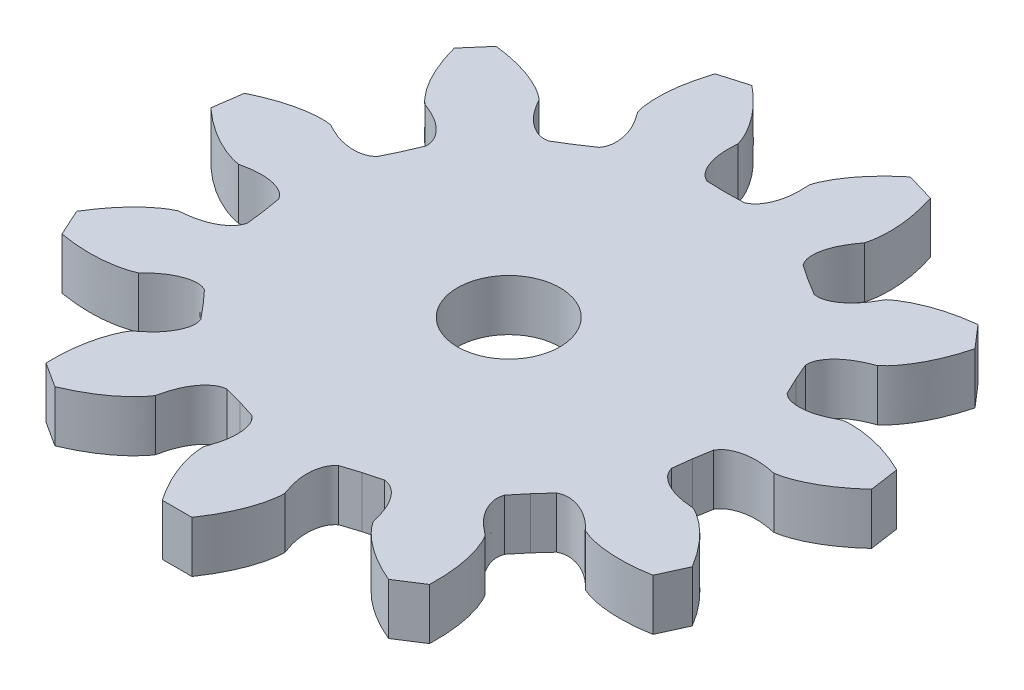
from build123d import *

# Parameters (mm, degrees)
ESBO_O1_R                = 4
RESSALTO_EXTRUS_O1_DEPTH = 4


with BuildPart() as part:
    # Esboço1 → Ressalto-extrusão1 (new body)
    with BuildSketch(Plane(origin=(0, 0, 0), x_dir=(1, 0, 0), z_dir=(0, 1, 0))):
        with BuildLine():
            Line((-18.79425391, 17.817601507), (-20.310943501, 16.067248601))
            add(Edge.make_bspline(
                [(-20.310943501, 16.067248601), (-20.071277367, 15.149373364), (-19.587508942, 13.795380648), (-18.623283394, 12.156256417), (-18.017526796, 11.428490265), (-17.661404245, 11.122721576)],
                knots=[0.009055561, 0.009055561, 0.009055561, 0.009055561, 0.503056033, 0.75005627, 0.997056506, 0.997056506, 0.997056506, 0.997056506], degree=3))
            add(Edge.make_bspline(
                [(-17.661404245, 11.122721576), (-17.338449221, 10.997306174), (-16.694924793, 10.741620444), (-15.801553421, 10.176642889), (-15.182066986, 9.539164967), (-14.886283931, 8.976589612), (-14.806778016, 8.61451277), (-14.804415739, 8.434534603), (-14.803014561, 8.344270523)],
                knots=[0.004160286, 0.004160286, 0.004160286, 0.004160286, 0.254421519, 0.504682752, 0.754943984, 0.880074601, 0.942639909, 1.005205217, 1.005205217, 1.005205217, 1.005205217], degree=3))
            Line((-14.803014561, 8.344270523), (-15.372758342, 7.0205046))
            Line((-15.372758342, 7.0205046), (-16.000091263, 5.723038543))
            add(Edge.make_bspline(
                [(-16.000091263, 5.723038543), (-16.069225887, 5.664987094), (-16.206791283, 5.548911773), (-16.532496032, 5.371888455), (-17.151358828, 5.22701792), (-18.03880983, 5.27773537), (-19.050825198, 5.582918909), (-19.665478418, 5.901823726), (-19.971751594, 6.063767268)],
                knots=[-0.005205218, -0.005205218, -0.005205218, -0.005205218, 0.057360091, 0.119925399, 0.245056015, 0.495317248, 0.745578481, 0.995839713, 0.995839713, 0.995839713, 0.995839713], degree=3))
            add(Edge.make_bspline(
                [(-19.971751594, 6.063767268), (-20.436046819, 6.132670877), (-21.382741993, 6.113885793), (-23.25294292, 5.769200941), (-24.593023331, 5.248132184), (-25.443655143, 4.828179416)],
                knots=[0.002943495, 0.002943495, 0.002943495, 0.002943495, 0.249943731, 0.496943967, 0.990944438, 0.990944438, 0.990944438, 0.990944438], degree=3))
            Line((-25.443655143, 4.828179416), (-25.773263393, 2.535704551))
            add(Edge.make_bspline(
                [(-25.773263393, 2.535704551), (-25.075402593, 1.89311206), (-23.936406968, 1.015605861), (-22.239071355, 0.157986499), (-21.336016389, -0.126752605), (-20.871116001, -0.191447208)],
                knots=[0.009055561, 0.009055561, 0.009055561, 0.009055561, 0.503056033, 0.75005627, 0.997056506, 0.997056506, 0.997056506, 0.997056506], degree=3))
            add(Edge.make_bspline(
                [(-20.871116001, -0.191447208), (-20.531624261, -0.12235069), (-19.85202292, 0.010468359), (-18.79502117, 0.018172024), (-17.929229433, -0.183188877), (-17.376249694, -0.496544989), (-17.113611541, -0.758159269), (-17.014320725, -0.908289395), (-16.964341533, -0.983466837)],
                knots=[0.004160286, 0.004160286, 0.004160286, 0.004160286, 0.254421519, 0.504682752, 0.754943984, 0.880074601, 0.942639909, 1.005205217, 1.005205217, 1.005205217, 1.005205217], degree=3))
            Line((-16.964341533, -0.983466837), (-16.727958611, -2.40511634))
            Line((-16.727958611, -2.40511634), (-16.554241537, -3.835776027))
            add(Edge.make_bspline(
                [(-16.554241537, -3.835776027), (-16.5810163, -3.921989013), (-16.633988619, -4.094011255), (-16.812282859, -4.419022029), (-17.254580448, -4.875477366), (-18.028571662, -5.312603367), (-19.044927844, -5.603003452), (-19.734419998, -5.667030268), (-20.079626678, -5.696378472)],
                knots=[-0.005205218, -0.005205218, -0.005205218, -0.005205218, 0.057360091, 0.119925399, 0.245056015, 0.495317248, 0.745578481, 0.995839713, 0.995839713, 0.995839713, 0.995839713], degree=3))
            add(Edge.make_bspline(
                [(-20.079626678, -5.696378472), (-20.50746878, -5.889430017), (-21.293723456, -6.417055088), (-22.680685893, -7.718129396), (-23.526322235, -8.880982497), (-24.014875643, -9.694155524)],
                knots=[0.002943495, 0.002943495, 0.002943495, 0.002943495, 0.249943731, 0.496943967, 0.990944438, 0.990944438, 0.990944438, 0.990944438], degree=3))
            Line((-24.014875643, -9.694155524), (-23.052754264, -11.800907778))
            add(Edge.make_bspline(
                [(-23.052754264, -11.800907778), (-22.11826467, -11.964198948), (-20.685664908, -12.086616612), (-18.794111294, -11.890443016), (-17.880471532, -11.641752419), (-17.454395895, -11.444832857)],
                knots=[0.009055561, 0.009055561, 0.009055561, 0.009055561, 0.503056033, 0.75005627, 0.997056506, 0.997056506, 0.997056506, 0.997056506], degree=3))
            add(Edge.make_bspline(
                [(-17.454395895, -11.444832857), (-17.206153667, -11.203162074), (-16.706244038, -10.724007355), (-15.821202497, -10.14606833), (-14.983988217, -9.847381547), (-14.349378953, -9.812030065), (-13.986994322, -9.890121097), (-13.822299097, -9.962737927), (-13.739609932, -9.998960425)],
                knots=[0.004160286, 0.004160286, 0.004160286, 0.004160286, 0.254421519, 0.504682752, 0.754943984, 0.880074601, 0.942639909, 1.005205217, 1.005205217, 1.005205217, 1.005205217], degree=3))
            Line((-13.739609932, -9.998960425), (-12.772150215, -11.067129835))
            Line((-12.772150215, -11.067129835), (-11.85253709, -12.17675881))
            add(Edge.make_bspline(
                [(-11.85253709, -12.17675881), (-11.828451194, -12.26376132), (-11.780012099, -12.437114637), (-11.754288668, -12.806924242), (-11.879594691, -13.430043037), (-12.294389376, -14.216228072), (-12.992400465, -15.010011806), (-13.537822665, -15.436642194), (-13.812362167, -15.647964295)],
                knots=[-0.005205218, -0.005205218, -0.005205218, -0.005205218, 0.057360091, 0.119925399, 0.245056015, 0.495317248, 0.745578481, 0.995839713, 0.995839713, 0.995839713, 0.995839713], degree=3))
            add(Edge.make_bspline(
                [(-13.812362167, -15.647964295), (-14.067914302, -16.041678493), (-14.444098176, -16.910626319), (-14.907471349, -18.755008183), (-14.990180058, -20.190447985), (-14.961542808, -21.138664581)],
                knots=[0.002943495, 0.002943495, 0.002943495, 0.002943495, 0.249943731, 0.496943967, 0.990944438, 0.990944438, 0.990944438, 0.990944438], degree=3))
            Line((-14.961542808, -21.138664581), (-13.013158538, -22.390815268))
            add(Edge.make_bspline(
                [(-13.013158538, -22.390815268), (-12.138733995, -22.022961324), (-10.867370397, -21.35142371), (-9.382153691, -20.163740888), (-8.748003301, -19.460578096), (-8.496028419, -19.064564938)],
                knots=[0.009055561, 0.009055561, 0.009055561, 0.009055561, 0.503056033, 0.75005627, 0.997056506, 0.997056506, 0.997056506, 0.997056506], degree=3))
            add(Edge.make_bspline(
                [(-8.496028419, -19.064564938), (-8.417850857, -18.727048657), (-8.256350714, -18.053686507), (-7.824263818, -17.089003678), (-7.281436614, -16.385100154), (-6.766681783, -16.012264924), (-6.419605232, -15.882039357), (-6.24179517, -15.854087561), (-6.152649257, -15.839854727)],
                knots=[0.004160286, 0.004160286, 0.004160286, 0.004160286, 0.254421519, 0.504682752, 0.754943984, 0.880074601, 0.942639909, 1.005205217, 1.005205217, 1.005205217, 1.005205217], degree=3))
            Line((-6.152649257, -15.839854727), (-4.761274369, -16.215407805))
            Line((-4.761274369, -16.215407805), (-3.387735863, -16.651706709))
            add(Edge.make_bspline(
                [(-3.387735863, -16.651706709), (-3.32043641, -16.711876059), (-3.185964971, -16.831521997), (-2.964390877, -17.128718497), (-2.732921557, -17.720664936), (-2.65682533, -18.606300812), (-2.814877738, -19.651447468), (-3.043062289, -20.305229293), (-3.159770262, -20.631432018)],
                knots=[-0.005205218, -0.005205218, -0.005205218, -0.005205218, 0.057360091, 0.119925399, 0.245056015, 0.495317248, 0.745578481, 0.995839713, 0.995839713, 0.995839713, 0.995839713], degree=3))
            add(Edge.make_bspline(
                [(-3.159770262, -20.631432018), (-3.161896432, -21.100807393), (-3.008573782, -22.035193179), (-2.401239983, -23.837304388), (-1.694761628, -25.089588897), (-1.158025845, -25.871796993)],
                knots=[0.002943495, 0.002943495, 0.002943495, 0.002943495, 0.249943731, 0.496943967, 0.990944438, 0.990944438, 0.990944438, 0.990944438], degree=3))
            Line((-1.158025845, -25.871796993), (1.158023077, -25.871797117))
            add(Edge.make_bspline(
                [(1.158023077, -25.871797117), (1.694758956, -25.089589087), (2.401237429, -23.837304642), (3.008571419, -22.035193498), (3.161894168, -21.10080773), (3.15976805, -20.631432355)],
                knots=[0.009055561, 0.009055561, 0.009055561, 0.009055561, 0.503056033, 0.75005627, 0.997056506, 0.997056506, 0.997056506, 0.997056506], degree=3))
            add(Edge.make_bspline(
                [(3.15976805, -20.631432355), (3.043060122, -20.305229611), (2.814875625, -19.651447754), (2.656823339, -18.606301103), (2.732919665, -17.720665234), (2.964389042, -17.128718806), (3.185963159, -16.831522338), (3.320434621, -16.711876414), (3.387734085, -16.651707073)],
                knots=[0.004160286, 0.004160286, 0.004160286, 0.004160286, 0.254421519, 0.504682752, 0.754943984, 0.880074601, 0.942639909, 1.005205217, 1.005205217, 1.005205217, 1.005205217], degree=3))
            Line((3.387734085, -16.651707073), (4.761272447, -16.215408369))
            Line((4.761272447, -16.215408369), (6.152647564, -15.839855383))
            add(Edge.make_bspline(
                [(6.152647564, -15.839855383), (6.241793473, -15.85408823), (6.419603524, -15.88204005), (6.766680072, -16.012265656), (7.281434862, -16.385100926), (7.824261986, -17.089004509), (8.256348782, -18.053687409), (8.417848862, -18.727049561), (8.496026376, -19.06456585)],
                knots=[-0.005205218, -0.005205218, -0.005205218, -0.005205218, 0.057360091, 0.119925399, 0.245056015, 0.495317248, 0.745578481, 0.995839713, 0.995839713, 0.995839713, 0.995839713], degree=3))
            add(Edge.make_bspline(
                [(8.496026376, -19.06456585), (8.748001214, -19.460579036), (9.38215153, -20.163741897), (10.867368112, -21.351424877), (12.138731644, -22.022962609), (13.013156142, -22.39081666)],
                knots=[0.002943495, 0.002943495, 0.002943495, 0.002943495, 0.249943731, 0.496943967, 0.990944438, 0.990944438, 0.990944438, 0.990944438], degree=3))
            Line((13.013156142, -22.39081666), (14.961540547, -21.138666183))
            add(Edge.make_bspline(
                [(14.961540547, -21.138666183), (14.990177913, -20.190449589), (14.907469338, -18.755009777), (14.44409636, -16.910627865), (14.06791258, -16.041680001), (13.812360489, -15.647965775)],
                knots=[0.009055561, 0.009055561, 0.009055561, 0.009055561, 0.503056033, 0.75005627, 0.997056506, 0.997056506, 0.997056506, 0.997056506], degree=3))
            add(Edge.make_bspline(
                [(13.812360489, -15.647965775), (13.537821014, -15.436643633), (12.992398842, -15.01001319), (12.294387858, -14.216229394), (11.879593261, -13.43004431), (11.754287292, -12.806925494), (11.780010759, -12.437115903), (11.828449881, -12.263762586), (11.852535791, -12.176760078)],
                knots=[0.004160286, 0.004160286, 0.004160286, 0.004160286, 0.254421519, 0.504682752, 0.754943984, 0.880074601, 0.942639909, 1.005205217, 1.005205217, 1.005205217, 1.005205217], degree=3))
            Line((11.852535791, -12.176760078), (12.772148903, -11.067131349))
            Line((12.772148903, -11.067131349), (13.739608862, -9.998961891))
            add(Edge.make_bspline(
                [(13.739608862, -9.998961891), (13.822298031, -9.962739408), (13.986993259, -9.890122603), (14.34937791, -9.812031606), (14.983987161, -9.847383143), (15.821201404, -10.14607002), (16.7062429, -10.724009159), (17.206152477, -11.203163913), (17.454394669, -11.444834728)],
                knots=[-0.005205218, -0.005205218, -0.005205218, -0.005205218, 0.057360091, 0.119925399, 0.245056015, 0.495317248, 0.745578481, 0.995839713, 0.995839713, 0.995839713, 0.995839713], degree=3))
            add(Edge.make_bspline(
                [(17.454394669, -11.444834728), (17.880470285, -11.641754338), (18.794110023, -11.890445034), (20.685663616, -12.086618829), (22.118263387, -11.964201299), (23.052753001, -11.800910244)],
                knots=[0.002943495, 0.002943495, 0.002943495, 0.002943495, 0.249943731, 0.496943967, 0.990944438, 0.990944438, 0.990944438, 0.990944438], degree=3))
            Line((23.052753001, -11.800910244), (24.014874607, -9.694158094))
            add(Edge.make_bspline(
                [(24.014874607, -9.694158094), (23.526321298, -8.880985006), (22.680685063, -7.718131824), (21.293722764, -6.417057371), (20.507468146, -5.889432216), (20.079626066, -5.696380624)],
                knots=[0.009055561, 0.009055561, 0.009055561, 0.009055561, 0.503056033, 0.75005627, 0.997056506, 0.997056506, 0.997056506, 0.997056506], degree=3))
            add(Edge.make_bspline(
                [(20.079626066, -5.696380624), (19.734419387, -5.667032372), (19.044927227, -5.603005493), (18.0285711, -5.3126053), (17.254579934, -4.87547921), (16.812282378, -4.419023826), (16.633988176, -4.094013045), (16.58101588, -3.921990788), (16.554241129, -3.835777795)],
                knots=[0.004160286, 0.004160286, 0.004160286, 0.004160286, 0.254421519, 0.504682752, 0.754943984, 0.880074601, 0.942639909, 1.005205217, 1.005205217, 1.005205217, 1.005205217], degree=3))
            Line((16.554241129, -3.835777795), (16.727958326, -2.405118322))
            Line((16.727958326, -2.405118322), (16.964341426, -0.983468649))
            add(Edge.make_bspline(
                [(16.964341426, -0.983468649), (17.014320628, -0.908291216), (17.113611462, -0.758161111), (17.376249649, -0.49654685), (17.929229407, -0.183190791), (18.795021165, 0.018170012), (19.852022938, 0.010466227), (20.531624254, -0.12235288), (20.871115982, -0.191449446)],
                knots=[-0.005205218, -0.005205218, -0.005205218, -0.005205218, 0.057360091, 0.119925399, 0.245056015, 0.495317248, 0.745578481, 0.995839713, 0.995839713, 0.995839713, 0.995839713], degree=3))
            add(Edge.make_bspline(
                [(20.871115982, -0.191449446), (21.336016378, -0.126754893), (22.239071376, 0.157984115), (23.93640708, 1.015603297), (25.075402785, 1.893109388), (25.773263664, 2.535701793)],
                knots=[0.002943495, 0.002943495, 0.002943495, 0.002943495, 0.249943731, 0.496943967, 0.990944438, 0.990944438, 0.990944438, 0.990944438], degree=3))
            Line((25.773263664, 2.535701793), (25.44365566, 4.828176694))
            add(Edge.make_bspline(
                [(25.44365566, 4.828176694), (24.5930239, 5.248129567), (23.252943535, 5.769198449), (21.382742645, 6.113883499), (20.436047475, 6.132668684), (19.971752243, 6.063765126)],
                knots=[0.009055561, 0.009055561, 0.009055561, 0.009055561, 0.503056033, 0.75005627, 0.997056506, 0.997056506, 0.997056506, 0.997056506], degree=3))
            add(Edge.make_bspline(
                [(19.971752243, 6.063765126), (19.665479042, 5.901821626), (19.050825782, 5.582916858), (18.038810402, 5.277733441), (17.151359393, 5.227016091), (16.532496599, 5.371886683), (16.206791878, 5.548910028), (16.069226492, 5.664985373), (16.000091876, 5.723036835)],
                knots=[0.004160286, 0.004160286, 0.004160286, 0.004160286, 0.254421519, 0.504682752, 0.754943984, 0.880074601, 0.942639909, 1.005205217, 1.005205217, 1.005205217, 1.005205217], degree=3))
            Line((16.000091876, 5.723036835), (15.372759174, 7.020502779))
            Line((15.372759174, 7.020502779), (14.803015451, 8.344268941))
            add(Edge.make_bspline(
                [(14.803015451, 8.344268941), (14.804416643, 8.434533018), (14.806778945, 8.614511178), (14.886284899, 8.976588023), (15.182067999, 9.539163343), (15.801554504, 10.176641193), (16.694925961, 10.74161866), (17.338450399, 10.997304327), (17.661405439, 11.122719683)],
                knots=[-0.005205218, -0.005205218, -0.005205218, -0.005205218, 0.057360091, 0.119925399, 0.245056015, 0.495317248, 0.745578481, 0.995839713, 0.995839713, 0.995839713, 0.995839713], degree=3))
            add(Edge.make_bspline(
                [(17.661405439, 11.122719683), (18.017528024, 11.428488334), (18.623284701, 12.156254423), (19.587510423, 13.795378552), (20.071278973, 15.149371221), (20.31094522, 16.067246428)],
                knots=[0.002943495, 0.002943495, 0.002943495, 0.002943495, 0.249943731, 0.496943967, 0.990944438, 0.990944438, 0.990944438, 0.990944438], degree=3))
            Line((20.31094522, 16.067246428), (18.794255817, 17.817599496))
            add(Edge.make_bspline(
                [(18.794255817, 17.817599496), (17.85161518, 17.711000084), (16.442556732, 17.424848978), (14.682892819, 16.703709556), (13.876326125, 16.207690609), (13.522988197, 15.898708294)],
                knots=[0.009055561, 0.009055561, 0.009055561, 0.009055561, 0.503056033, 0.75005627, 0.997056506, 0.997056506, 0.997056506, 0.997056506], degree=3))
            add(Edge.make_bspline(
                [(13.522988197, 15.898708294), (13.352888051, 15.596888958), (13.008221758, 14.996302555), (12.321854857, 14.192429104), (11.60270343, 13.669970715), (11.003759963, 13.457261126), (10.63405367, 13.430093373), (10.455571234, 13.453368705), (10.366026503, 13.464827707)],
                knots=[0.004160286, 0.004160286, 0.004160286, 0.004160286, 0.254421519, 0.504682752, 0.754943984, 0.880074601, 0.942639909, 1.005205217, 1.005205217, 1.005205217, 1.005205217], degree=3))
            Line((10.366026503, 13.464827707), (9.136817604, 14.217163851))
            Line((9.136817604, 14.217163851), (7.941836663, 15.022760099))
            add(Edge.make_bspline(
                [(7.941836663, 15.022760099), (7.894214977, 15.099452615), (7.798898732, 15.252137034), (7.670029875, 15.599719624), (7.614707272, 16.232900516), (7.791205937, 17.1041007), (8.237307952, 18.062383065), (8.640441051, 18.625395114), (8.844323458, 18.905503902)],
                knots=[-0.005205218, -0.005205218, -0.005205218, -0.005205218, 0.057360091, 0.119925399, 0.245056015, 0.495317248, 0.745578481, 0.995839713, 0.995839713, 0.995839713, 0.995839713], degree=3))
            add(Edge.make_bspline(
                [(8.844323458, 18.905503902), (8.978601828, 19.355267265), (9.094736719, 20.294999843), (9.019717605, 22.195218591), (8.694665904, 23.595814731), (8.400045178, 24.497553847)],
                knots=[0.002943495, 0.002943495, 0.002943495, 0.002943495, 0.249943731, 0.496943967, 0.990944438, 0.990944438, 0.990944438, 0.990944438], degree=3))
            Line((8.400045178, 24.497553847), (6.177812547, 25.150060351))
            add(Edge.make_bspline(
                [(6.177812547, 25.150060351), (5.442444773, 24.550753214), (4.411774344, 23.548233074), (3.321328268, 21.990225851), (2.910969276, 21.136885283), (2.780770946, 20.685923912)],
                knots=[0.009055561, 0.009055561, 0.009055561, 0.009055561, 0.503056033, 0.75005627, 0.997056506, 0.997056506, 0.997056506, 0.997056506], degree=3))
            add(Edge.make_bspline(
                [(2.780770946, 20.685923912), (2.80084945, 20.340054248), (2.835599238, 19.648468149), (2.692797457, 18.601128806), (2.370271109, 17.772806225), (1.981407288, 17.270050246), (1.685078558, 17.047316965), (1.522345984, 16.970402531), (1.440820959, 16.93163092)],
                knots=[0.004160286, 0.004160286, 0.004160286, 0.004160286, 0.254421519, 0.504682752, 0.754943984, 0.880074601, 0.942639909, 1.005205217, 1.005205217, 1.005205217, 1.005205217], degree=3))
            Line((1.440820959, 16.93163092), (1.001e-06, 16.899975855))
            Line((1.001e-06, 16.899975855), (-1.44081915, 16.931631072))
            add(Edge.make_bspline(
                [(-1.44081915, 16.931631072), (-1.522344167, 16.970402694), (-1.685076724, 17.047317149), (-1.98140544, 17.270050467), (-2.37026921, 17.772806471), (-2.692795465, 18.601129087), (-2.83559713, 19.648468469), (-2.800847281, 20.340054553), (-2.780768729, 20.685924212)],
                knots=[-0.005205218, -0.005205218, -0.005205218, -0.005205218, 0.057360091, 0.119925399, 0.245056015, 0.495317248, 0.745578481, 0.995839713, 0.995839713, 0.995839713, 0.995839713], degree=3))
            add(Edge.make_bspline(
                [(-2.780768729, 20.685924212), (-2.910967009, 21.136885597), (-3.32132591, 21.990226212), (-4.411771822, 23.54823355), (-5.442442156, 24.550753784), (-6.177809855, 25.150061012)],
                knots=[0.002943495, 0.002943495, 0.002943495, 0.002943495, 0.249943731, 0.496943967, 0.990944438, 0.990944438, 0.990944438, 0.990944438], degree=3))
            Line((-6.177809855, 25.150061012), (-8.400042557, 24.497554746))
            add(Edge.make_bspline(
                [(-8.400042557, 24.497554746), (-8.694663394, 23.595815666), (-9.019715226, 22.195219554), (-9.094734541, 20.295000815), (-8.978599751, 19.355268226), (-8.844321431, 18.905504849)],
                knots=[0.009055561, 0.009055561, 0.009055561, 0.009055561, 0.503056033, 0.75005627, 0.997056506, 0.997056506, 0.997056506, 0.997056506], degree=3))
            add(Edge.make_bspline(
                [(-8.844321431, 18.905504849), (-8.640439061, 18.625396031), (-8.237306005, 18.062383935), (-7.791204109, 17.104101541), (-7.614705542, 16.232901335), (-7.670028202, 15.599720437), (-7.79889709, 15.252137872), (-7.89421336, 15.099453459), (-7.94183506, 15.022760949)],
                knots=[0.004160286, 0.004160286, 0.004160286, 0.004160286, 0.254421519, 0.504682752, 0.754943984, 0.880074601, 0.942639909, 1.005205217, 1.005205217, 1.005205217, 1.005205217], degree=3))
            Line((-7.94183506, 15.022760949), (-9.136815919, 14.217164934))
            Line((-9.136815919, 14.217164934), (-10.366025064, 13.464828813))
            add(Edge.make_bspline(
                [(-10.366025064, 13.464828813), (-10.455569794, 13.453369825), (-10.634052226, 13.43009452), (-11.003758528, 13.45726231), (-11.602701966, 13.669971949), (-12.321853333, 14.192430418), (-13.008220158, 14.996303964), (-13.352886391, 15.596890387), (-13.522986493, 15.898709744)],
                knots=[-0.005205218, -0.005205218, -0.005205218, -0.005205218, 0.057360091, 0.119925399, 0.245056015, 0.495317248, 0.745578481, 0.995839713, 0.995839713, 0.995839713, 0.995839713], degree=3))
            add(Edge.make_bspline(
                [(-13.522986493, 15.898709744), (-13.876324388, 16.207692099), (-14.682891031, 16.703711133), (-16.442554868, 17.424850742), (-17.851613286, 17.711001978), (-18.79425391, 17.817601507)],
                knots=[0.002943495, 0.002943495, 0.002943495, 0.002943495, 0.249943731, 0.496943967, 0.990944438, 0.990944438, 0.990944438, 0.990944438], degree=3))
        make_face()
        with Locations((-1.68e-07, 6.5e-08)):
            Circle(ESBO_O1_R, mode=Mode.SUBTRACT)
    extrude(amount=RESSALTO_EXTRUS_O1_DEPTH)


solid = part.part
